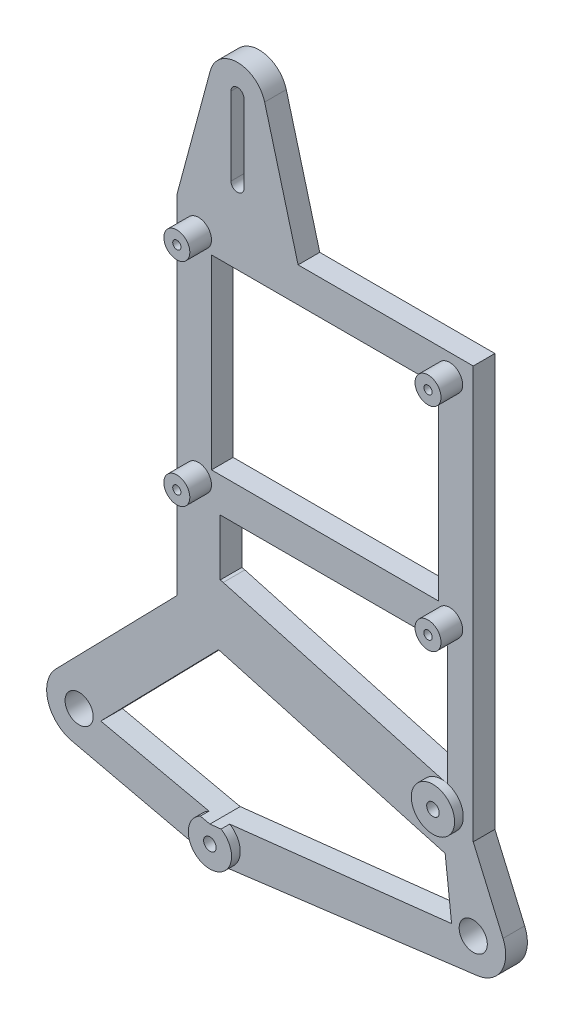
from build123d import *

# Parameters (mm, degrees)
SKETCH1_R           = 3.25
SKETCH1_R_2         = 1.45
SKETCH1_R_3         = 0.95
SKETCH1_W           = 52.44
SKETCH1_H           = 43
BOSS_EXTRUDE1_DEPTH = 5
SKETCH2_R           = 5
SKETCH2_R_2         = 1.45
BOSS_EXTRUDE2_DEPTH = 2
SKETCH3_R           = 3
SKETCH3_R_2         = 0.945605266
SKETCH3_R_3         = 0.976454059
SKETCH3_R_4         = 0.939469919
SKETCH3_R_5         = 0.95
BOSS_EXTRUDE3_DEPTH = 5


with BuildPart() as part:
    # Sketch1 → Boss-Extrude1 (new body)
    with BuildSketch(Plane.XY):
        with BuildLine():
            Line((-5.367112971, 5.238711517), (22.56, 33.850321407))
            Line((22.56, 33.850321407), (22.56, 114))
            Line((22.56, 114), (30.283459854, 142.689687483))
            ThreePointArc((30.283459854, 142.689687483), (36.56, 147.5), (42.836540146, 142.689687483))
            Line((42.836540146, 142.689687483), (50.56, 114))
            Line((50.56, 114), (91, 114))
            Line((91, 114), (91, 18.850321407))
            Line((91, 18.850321407), (97.880809624, 2.984034001))
            ThreePointArc((97.880809624, 2.984034001), (97.517806061, -3.71055308), (91.9464361, -7.440044268))
            Line((91.9464361, -7.440044268), (32.8309574, -14.960029512))
            ThreePointArc((32.8309574, -14.960029512), (31.949174794, -14.993704709), (31.075204637, -14.871841068))
            Line((31.075204637, -14.871841068), (-1.687193044, -7.307761602))
            ThreePointArc((-1.687193044, -7.307761602), (-7.196826055, -2.11085166), (-5.367112971, 5.238711517))
        make_face()
        Circle(SKETCH1_R, mode=Mode.SUBTRACT)
        with Locations((91, 0)):
            Circle(SKETCH1_R, mode=Mode.SUBTRACT)
        with Locations((32.2, -10)):
            Circle(SKETCH1_R_2, mode=Mode.SUBTRACT)
        with Locations((83.7, 22.7)):
            Circle(SKETCH1_R_2, mode=Mode.SUBTRACT)
        with Locations((27.56, 109)):
            Circle(SKETCH1_R_3, mode=Mode.SUBTRACT)
        with Locations((27.56, 60)):
            Circle(SKETCH1_R_3, mode=Mode.SUBTRACT)
        with Locations((85.56, 60)):
            Circle(SKETCH1_R_3, mode=Mode.SUBTRACT)
        with Locations((85.56, 109)):
            Circle(SKETCH1_R_3, mode=Mode.SUBTRACT)
        with BuildLine():
            Line((33.273349419, 41.853300017), (85, 27.444671021))
            Line((85, 27.444671021), (85, 55))
            Line((85, 55), (32.56, 55))
            Line((32.56, 55), (32.56, 41.983767061))
            ThreePointArc((32.56, 41.983767061), (32.919637445, 41.934732767), (33.273349419, 41.853300017))
        make_face(mode=Mode.SUBTRACT)
        with Locations((56.78, 84.5)):
            Rectangle(SKETCH1_W, SKETCH1_H, mode=Mode.SUBTRACT)
        Polygon((32.2, -6), (5, 0), (32.2, 27.866675292), (84.517456272, 13.293475424), (86, 0), align=None, mode=Mode.SUBTRACT)
        with BuildLine():
            Line((38.06, 141), (38.06, 123))
            ThreePointArc((38.06, 123), (36.56, 121.5), (35.06, 123))
            Line((35.06, 123), (35.06, 141))
            ThreePointArc((35.06, 141), (36.56, 142.5), (38.06, 141))
        make_face(mode=Mode.SUBTRACT)
    extrude(amount=BOSS_EXTRUDE1_DEPTH)

    # Sketch2 → Boss-Extrude2 (add)
    with BuildSketch(Plane.XY.offset(5)):
        with Locations((83.7, 22.7)):
            Circle(SKETCH2_R)
        with Locations((83.7, 22.7)):
            Circle(SKETCH2_R_2, mode=Mode.SUBTRACT)
        with BuildLine():
            Line((32.2, -6), (34.773281255, -5.71301696))
            ThreePointArc((34.773281255, -5.71301696), (31.991216079, -14.995639026), (29.993401427, -5.513250315))
            Line((29.993401427, -5.513250315), (32.2, -6))
        make_face()
        with Locations((32.2, -10)):
            Circle(SKETCH2_R_2, mode=Mode.SUBTRACT)
    extrude(amount=BOSS_EXTRUDE2_DEPTH)

    # Sketch3 → Boss-Extrude3 (add)
    with BuildSketch(Plane.XY.offset(5)):
        with Locations((27.56, 60)):
            Circle(SKETCH3_R)
        with Locations((27.56, 60)):
            Circle(SKETCH3_R_2, mode=Mode.SUBTRACT)
        with Locations((85.56, 60)):
            Circle(SKETCH3_R)
        with Locations((85.56, 60)):
            Circle(SKETCH3_R_3, mode=Mode.SUBTRACT)
        with Locations((85.56, 109)):
            Circle(SKETCH3_R)
        with Locations((85.56, 109)):
            Circle(SKETCH3_R_4, mode=Mode.SUBTRACT)
        with Locations((27.56, 109)):
            Circle(SKETCH3_R)
        with Locations((27.56, 109)):
            Circle(SKETCH3_R_5, mode=Mode.SUBTRACT)
    extrude(amount=BOSS_EXTRUDE3_DEPTH)


solid = part.part
